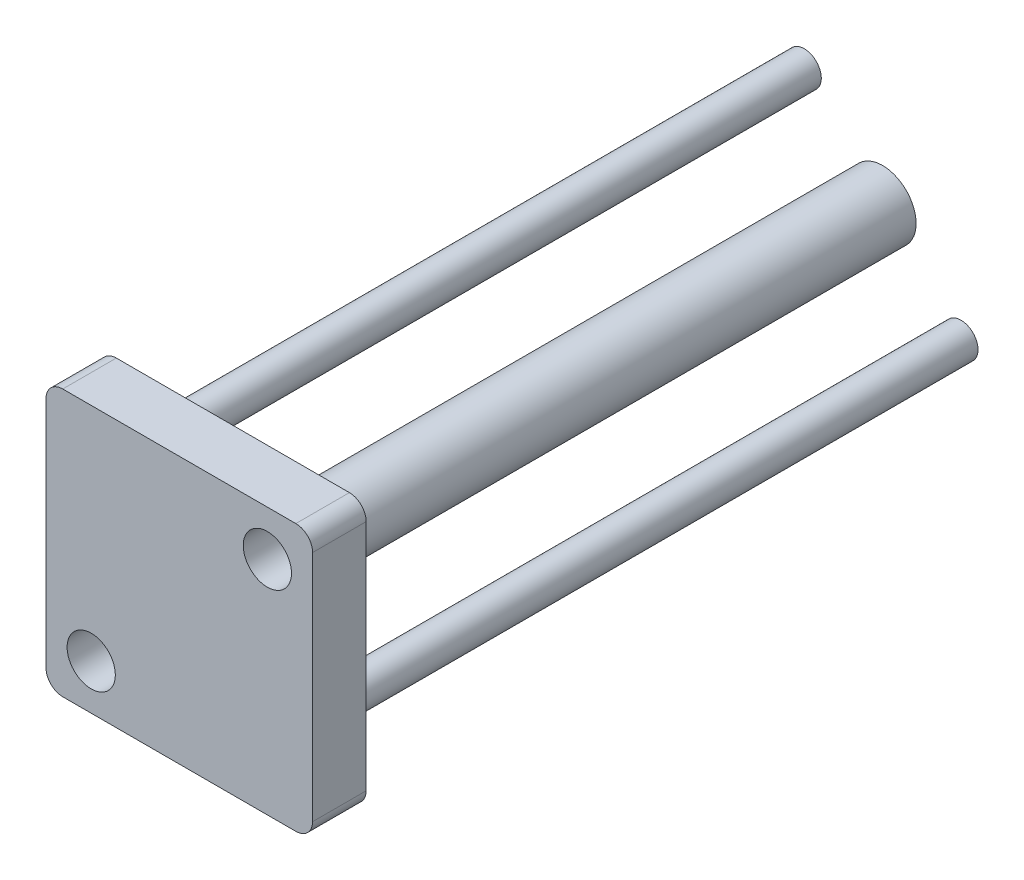
from build123d import *

# Parameters (mm, degrees)
SKETCH1_R           = 5
BOSS_EXTRUDE1_DEPTH = 97
SKETCH2_R           = 3.6
BOSS_EXTRUDE2_DEPTH = 8
BOSS_EXTRUDE3_REACH = 107
SKETCH4_R           = 2.55


with BuildPart() as part:
    # Sketch1 → Boss-Extrude1 (new body)
    with BuildSketch(Plane.XY):
        Circle(SKETCH1_R)
    extrude(amount=BOSS_EXTRUDE1_DEPTH)

    # Sketch2 → Boss-Extrude2 (add)
    with BuildSketch(Plane.XY.offset(97)):
        with BuildLine():
            Line((-17.4, -19.9), (17.4, -19.9))
            ThreePointArc((17.4, -19.9), (19.167766953, -19.167766953), (19.9, -17.4))
            Line((19.9, -17.4), (19.9, 17.4))
            ThreePointArc((19.9, 17.4), (19.167766953, 19.167766953), (17.4, 19.9))
            Line((17.4, 19.9), (-17.4, 19.9))
            ThreePointArc((-17.4, 19.9), (-19.167766953, 19.167766953), (-19.9, 17.4))
            Line((-19.9, 17.4), (-19.9, -17.4))
            ThreePointArc((-19.9, -17.4), (-19.167766953, -19.167766953), (-17.4, -19.9))
        make_face()
        with Locations((13.15, 13.15)):
            Circle(SKETCH2_R, mode=Mode.SUBTRACT)
        with Locations((-13.15, -13.15)):
            Circle(SKETCH2_R, mode=Mode.SUBTRACT)
    extrude(amount=BOSS_EXTRUDE2_DEPTH)

    # Sketch4 → Boss-Extrude3 (add, up to next)
    with BuildSketch(Plane(origin=(0, 0, 0), x_dir=(-1, 0, 0), z_dir=(0, 0, -1)), mode=Mode.PRIVATE) as boss_extrude3_sk1:
        with Locations((-11.7, -11.7)):
            Circle(SKETCH4_R)
    boss_extrude3_tool1 = extrude(boss_extrude3_sk1.sketch, amount=-BOSS_EXTRUDE3_REACH, mode=Mode.PRIVATE) - part.part
    add(boss_extrude3_tool1.solids().sort_by_distance((11.7, -11.7, 0))[0])
    # Sketch4 → Boss-Extrude3 (add, up to next)
    with BuildSketch(Plane(origin=(0, 0, 0), x_dir=(-1, 0, 0), z_dir=(0, 0, -1)), mode=Mode.PRIVATE) as boss_extrude3_sk2:
        with Locations((11.7, 11.7)):
            Circle(SKETCH4_R)
    boss_extrude3_tool2 = extrude(boss_extrude3_sk2.sketch, amount=-BOSS_EXTRUDE3_REACH, mode=Mode.PRIVATE) - part.part
    add(boss_extrude3_tool2.solids().sort_by_distance((-11.7, 11.7, 0))[0])


solid = part.part
